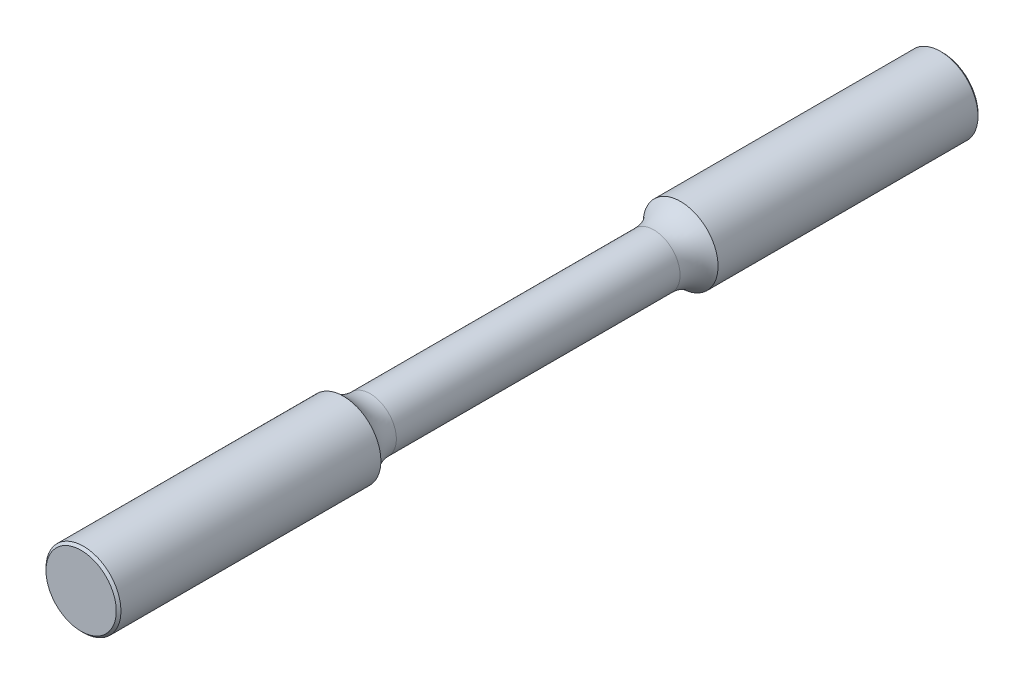
from build123d import *

# Parameters (mm, degrees)
CHAMFER1_SIZE = 0.396875


with BuildPart() as part:
    # Sketch1 → Revolve1 (revolve)
    with BuildSketch(Plane(origin=(0, 0, 0), x_dir=(1, 0, 0), z_dir=(0, 1, 0))):
        with BuildLine():
            Line((0, 73.025), (0, -73.025))
            Line((0, -73.025), (6.35, -73.025))
            Line((6.35, -73.025), (6.35, -28.575))
            ThreePointArc((6.35, -28.575), (4.94058927, -26.499537373), (4.445, -24.040192948))
            Line((4.445, -24.040192948), (4.445, 24.040192948))
            ThreePointArc((4.445, 24.040192948), (4.94058927, 26.499537373), (6.35, 28.575))
            Line((6.35, 28.575), (6.35, 73.025))
            Line((6.35, 73.025), (0, 73.025))
        make_face()
    revolve(axis=Axis((0, 0, -73.025), (0, 0, 1)))

    # Chamfer1
    chamfer1_edges = [part.edges().sort_by_distance(p)[0] for p in [
        (-6.35, 0, 73.025),
        (-6.35, 0, -73.025),
    ]]
    chamfer(chamfer1_edges, length=CHAMFER1_SIZE)


solid = part.part
